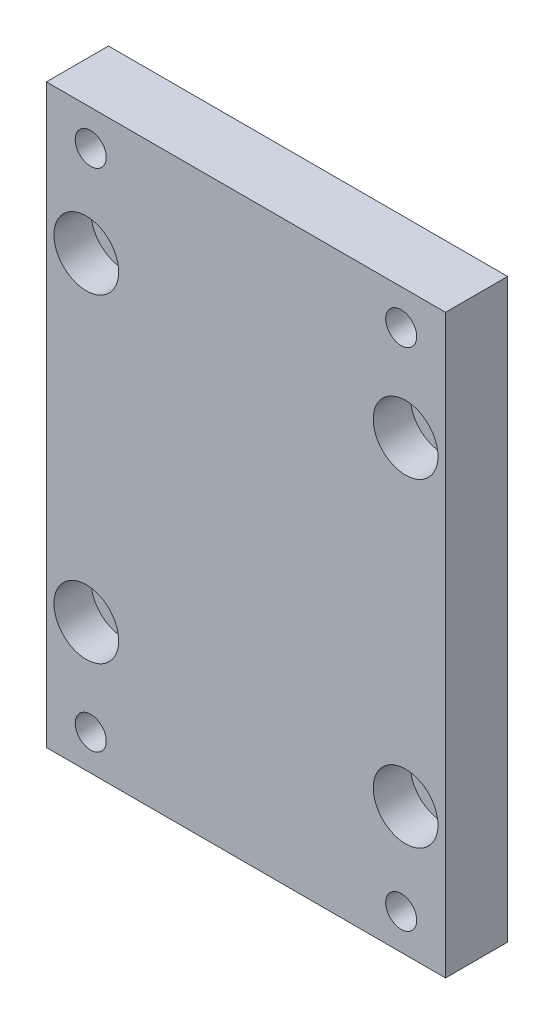
from build123d import *

# Parameters (mm, degrees)
SKETCH_2_W                = 45
SKETCH_2_H                = 65
SKETCH_2_R                = 2.25
SKETCH_2_R_2              = 1.75
EXTRUDE_1_DEPTH           = 7
HOLE_WIZARD_1_D           = 4.5
HOLE_WIZARD_1_CBORE_D     = 7.3
HOLE_WIZARD_1_CBORE_DEPTH = 4.2
CUT_EXTRUDE_1_DEPTH       = 2.5


with BuildPart() as part:
    # 草圖2 → 填料-伸長1 (new body)
    with BuildSketch(Plane.XY):
        Rectangle(SKETCH_2_W, SKETCH_2_H)
        with Locations((-18, 18)):
            Circle(SKETCH_2_R, mode=Mode.SUBTRACT)
        with Locations((-17.5, 28.5)):
            Circle(SKETCH_2_R_2, mode=Mode.SUBTRACT)
        with Locations((18, 18)):
            Circle(SKETCH_2_R, mode=Mode.SUBTRACT)
        with Locations((18, -18)):
            Circle(SKETCH_2_R, mode=Mode.SUBTRACT)
        with Locations((-18, -18)):
            Circle(SKETCH_2_R, mode=Mode.SUBTRACT)
        with Locations((17.5, 28.5)):
            Circle(SKETCH_2_R_2, mode=Mode.SUBTRACT)
        with Locations((17.5, -28.5)):
            Circle(SKETCH_2_R_2, mode=Mode.SUBTRACT)
        with Locations((-17.5, -28.5)):
            Circle(SKETCH_2_R_2, mode=Mode.SUBTRACT)
    extrude(amount=EXTRUDE_1_DEPTH)

    # 鑽孔1 (through all)
    with Locations(Plane(origin=(-18, 18, 7), x_dir=(1, 0, 0), z_dir=(0, 0, 1))):
        with Locations((0, 0), (36, 0), (36, -36), (0, -36)):
            CounterBoreHole(HOLE_WIZARD_1_D / 2, HOLE_WIZARD_1_CBORE_D / 2, HOLE_WIZARD_1_CBORE_DEPTH)

    # 草圖4 → 除料-伸長1 (cut)
    with BuildSketch(Plane(origin=(0, 0, 0), x_dir=(-1, 0, 0), z_dir=(0, 0, -1))):
        Polygon((-14.209103466, 28.5), (-15.854551733, 31.35), (-19.145448267, 31.35), (-20.790896534, 28.5), (-19.145448267, 25.65), (-15.854551733, 25.65), align=None)
        Polygon((15.854551733, 25.65), (14.209103466, 28.5), (15.854551733, 31.35), (19.145448267, 31.35), (20.790896534, 28.5), (19.145448267, 25.65), align=None)
        Polygon((14.209103466, -28.5), (15.854551733, -31.35), (19.145448267, -31.35), (20.790896534, -28.5), (19.145448267, -25.65), (15.854551733, -25.65), align=None)
        Polygon((-15.854551733, -25.65), (-14.209103466, -28.5), (-15.854551733, -31.35), (-19.145448267, -31.35), (-20.790896534, -28.5), (-19.145448267, -25.65), align=None)
    extrude(amount=-CUT_EXTRUDE_1_DEPTH, mode=Mode.SUBTRACT)


solid = part.part
